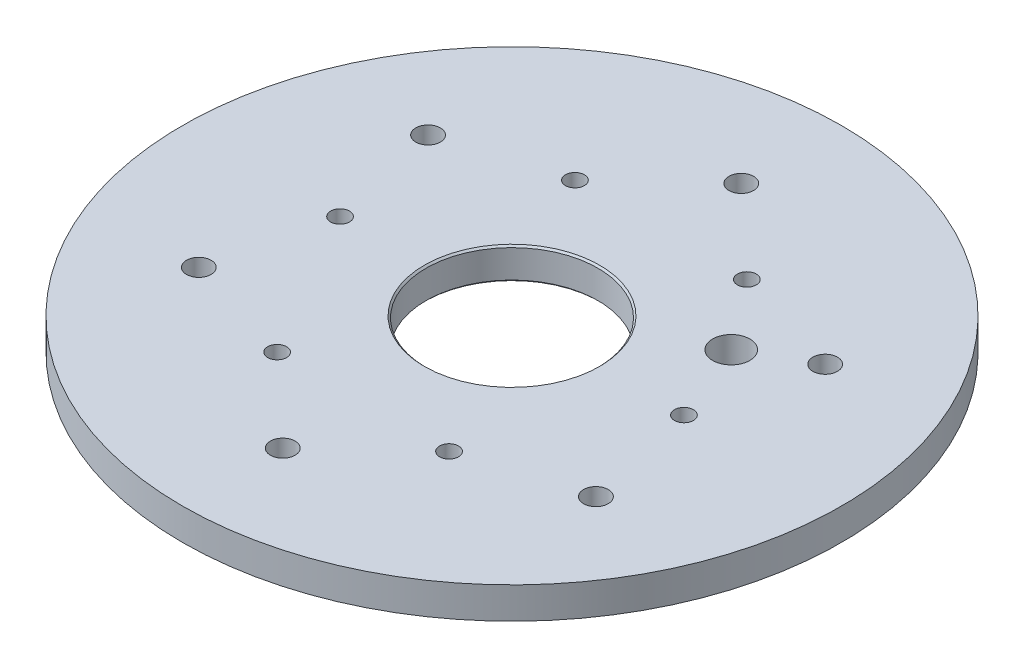
from build123d import *

# Parameters (mm, degrees)
SKETCH1_R           = 57.5
SKETCH1_R_2         = 1.65
SKETCH1_R_3         = 2.15
SKETCH1_R_4         = 15
BOSS_EXTRUDE1_DEPTH = 5.5
CHAMFER2_SIZE       = 0.3
SKETCH3_R           = 3.25
CUT_EXTRUDE2_DEPTH  = 10


with BuildPart() as part:
    # Sketch1 → Boss-Extrude1 (new body)
    with BuildSketch(Plane(origin=(0, 0, 0), x_dir=(1, 0, 0), z_dir=(0, 1, 0))):
        Circle(SKETCH1_R)
        with Locations((-30, 0)):
            Circle(SKETCH1_R_2, mode=Mode.SUBTRACT)
        with Locations((-15, 25.980762114)):
            Circle(SKETCH1_R_2, mode=Mode.SUBTRACT)
        with Locations((15, 25.980762114)):
            Circle(SKETCH1_R_2, mode=Mode.SUBTRACT)
        with Locations((30, 0)):
            Circle(SKETCH1_R_2, mode=Mode.SUBTRACT)
        with Locations((15, -25.980762114)):
            Circle(SKETCH1_R_2, mode=Mode.SUBTRACT)
        with Locations((-15, -25.980762114)):
            Circle(SKETCH1_R_2, mode=Mode.SUBTRACT)
        with Locations((-34.641016151, 20)):
            Circle(SKETCH1_R_3, mode=Mode.SUBTRACT)
        with Locations((0, 40)):
            Circle(SKETCH1_R_3, mode=Mode.SUBTRACT)
        with Locations((34.641016151, 20)):
            Circle(SKETCH1_R_3, mode=Mode.SUBTRACT)
        with Locations((34.641016151, -20)):
            Circle(SKETCH1_R_3, mode=Mode.SUBTRACT)
        with Locations((0, -40)):
            Circle(SKETCH1_R_3, mode=Mode.SUBTRACT)
        with Locations((-34.641016151, -20)):
            Circle(SKETCH1_R_3, mode=Mode.SUBTRACT)
        Circle(SKETCH1_R_4, mode=Mode.SUBTRACT)
    extrude(amount=BOSS_EXTRUDE1_DEPTH)

    # Chamfer2
    chamfer2_edges = [part.edges().sort_by_distance(p)[0] for p in [
        (-15, 0, 0),
        (-15, 5.5, 0),
    ]]
    chamfer(chamfer2_edges, length=CHAMFER2_SIZE)

    # Sketch3 → Cut-Extrude2 (cut)
    with BuildSketch(Plane.XZ):
        with Locations((24.248711306, -14)):
            Circle(SKETCH3_R)
    extrude(amount=-CUT_EXTRUDE2_DEPTH, mode=Mode.SUBTRACT)


solid = part.part
